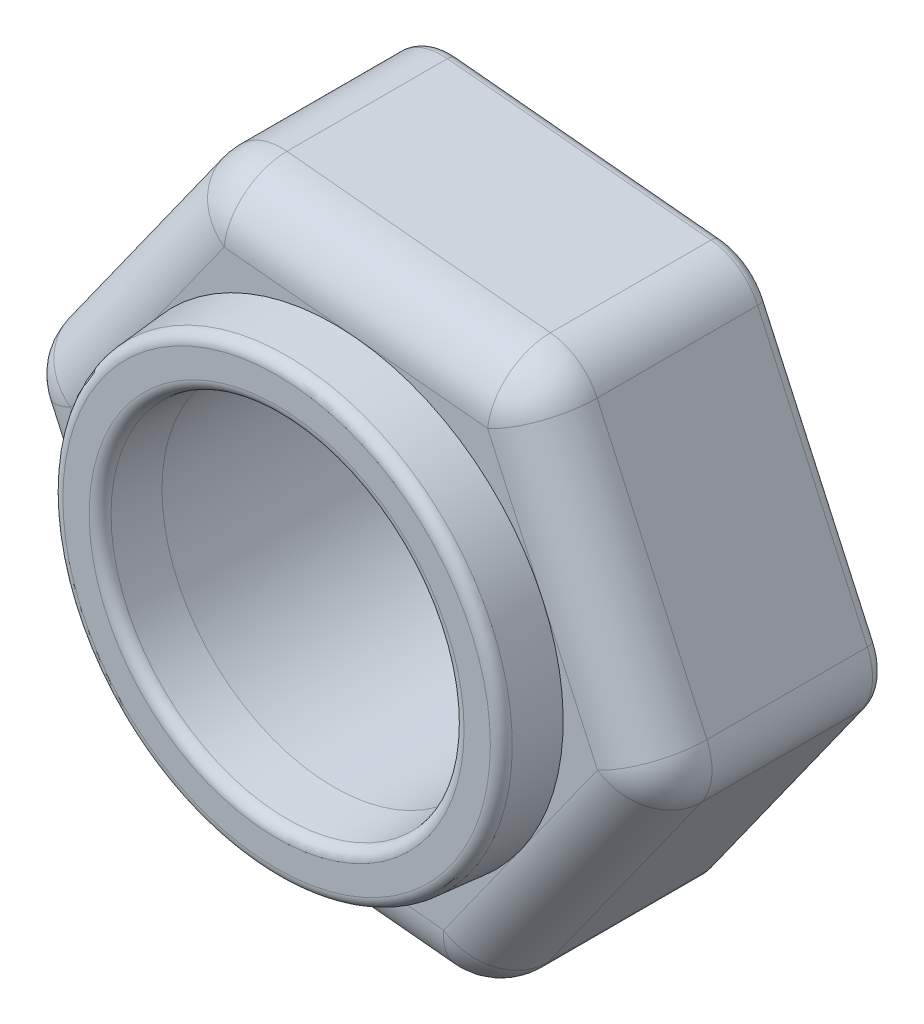
from build123d import *

# Parameters (mm, degrees)
SKETCH1_R           = 1.5
BOSS_EXTRUDE1_DEPTH = 2
FILLET1_R           = 0.5
SKETCH3_R           = 2
SKETCH3_R_2         = 1.5
BOSS_EXTRUDE2_DEPTH = 0.5
BOSS_EXTRUDE2_TAPER = 5
FILLET2_R           = 0.1


with BuildPart() as part:
    # Sketch1 → Boss-Extrude1 (new body)
    with BuildSketch(Plane.XY):
        with BuildLine():
            Line((2.753751395, -0.013659805), (1.795799026, 2.087687523))
            ThreePointArc((1.795799026, 2.087687523), (1.631145222, 2.287378341), (1.388705435, 2.377988761))
            Line((1.388705435, 2.377988761), (-0.910090917, 2.599051338))
            ThreePointArc((-0.910090917, 2.599051338), (-1.165355141, 2.55630237), (-1.365045959, 2.391648566))
            Line((-1.365045959, 2.391648566), (-2.705889943, 0.511363815))
            ThreePointArc((-2.705889943, 0.511363815), (-2.796500362, 0.268924029), (-2.753751395, 0.013659805))
            Line((-2.753751395, 0.013659805), (-1.795799026, -2.087687523))
            ThreePointArc((-1.795799026, -2.087687523), (-1.631145222, -2.287378341), (-1.388705435, -2.377988761))
            Line((-1.388705435, -2.377988761), (0.910090917, -2.599051338))
            ThreePointArc((0.910090917, -2.599051338), (1.165355141, -2.55630237), (1.365045959, -2.391648566))
            Line((1.365045959, -2.391648566), (2.705889943, -0.511363815))
            ThreePointArc((2.705889943, -0.511363815), (2.796500362, -0.268924029), (2.753751395, -0.013659805))
        make_face()
        Circle(SKETCH1_R, mode=Mode.SUBTRACT)
    extrude(amount=BOSS_EXTRUDE1_DEPTH)

    # Fillet1
    fillet1_edges = [part.edges().sort_by_distance(p)[0] for p in [
        (1.165355141, -2.55630237, 2),
        (2.035467951, -1.45150619, 2),
        (2.796500362, -0.268924029, 2),
        (2.27477521, 1.037013859, 2),
        (1.631145222, 2.287378341, 2),
        (0.239307259, 2.488520049, 2),
        (-1.165355141, 2.55630237, 2),
        (-2.035467951, 1.45150619, 2),
        (-2.796500362, 0.268924029, 2),
        (-2.27477521, -1.037013859, 2),
        (-1.631145222, -2.287378341, 2),
        (-0.239307259, -2.488520049, 2),
    ]]
    fillet(fillet1_edges, radius=FILLET1_R)

    # Sketch3 → Boss-Extrude2 (add)
    with BuildSketch(Plane.XY.offset(2)):
        Circle(SKETCH3_R)
        Circle(SKETCH3_R_2, mode=Mode.SUBTRACT)
    extrude(amount=BOSS_EXTRUDE2_DEPTH, taper=BOSS_EXTRUDE2_TAPER)

    # Fillet2
    fillet2_edges = [part.edges().sort_by_distance(p)[0] for p in [
        (-2.27477521, -1.037013859, 0),
        (-2.796500362, 0.268924029, 0),
        (-2.035467951, 1.45150619, 0),
        (-1.165355141, 2.55630237, 0),
        (0.239307259, 2.488520049, 0),
        (1.631145222, 2.287378341, 0),
        (2.27477521, 1.037013859, 0),
        (2.796500362, -0.268924029, 0),
        (2.035467951, -1.45150619, 0),
        (1.165355141, -2.55630237, 0),
        (-0.239307259, -2.488520049, 0),
        (-1.631145222, -2.287378341, 0),
        (-1.956255668, 0, 2.5),
        (-1.543744332, 0, 2.5),
    ]]
    fillet(fillet2_edges, radius=FILLET2_R)


solid = part.part
